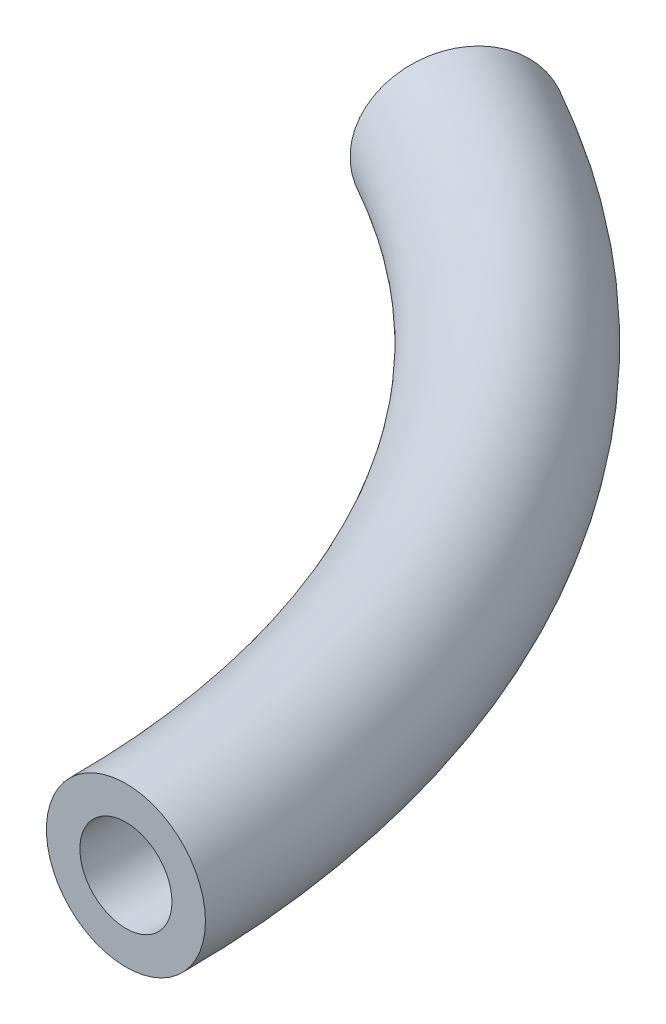
from build123d import *

# Parameters (mm, degrees)
SKIZZE2_R   = 2.85
SKIZZE2_R_2 = 1.65


with BuildPart() as part:
    # Austragung-Dünn1: sweep along a path in Skizze1
    with BuildLine(Plane(origin=(0, 0, 0), x_dir=(1, 0, 0), z_dir=(0, 1, 0))) as austragung_d_nn1_path:
        ThreePointArc((16.11532863, 28.797503071), (28.467576686, 16.691227564), (33, 0))
    # Skizze2 → Austragung-Dünn1 (sweep)
    with BuildSketch(Plane.XY):
        with Locations((33, 0)):
            Circle(SKIZZE2_R)
        with Locations((33, 0)):
            Circle(SKIZZE2_R_2, mode=Mode.SUBTRACT)
    sweep(path=austragung_d_nn1_path.line)


solid = part.part
